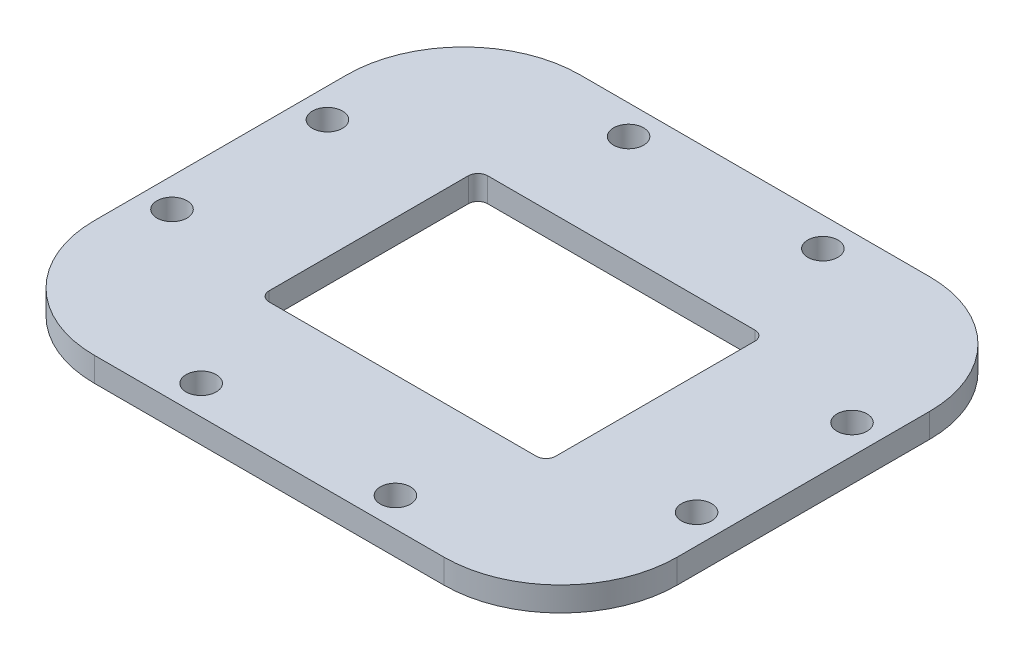
from build123d import *

# Parameters (mm, degrees)
SKETCH_1_W          = 60
SKETCH_1_H          = 50
SKETCH_1_W_2        = 29.5
SKETCH_1_H_2        = 22.5
EXTRUDE_1_DEPTH     = 2.5
SKETCH_8_R          = 1.55
CUT_EXTRUDE_2_DEPTH = 10
FILLET_1_R          = 1
FILLET_2_R          = 12


with BuildPart() as part:
    # 草图1 → 凸台-拉伸1 (new body)
    with BuildSketch(Plane(origin=(0, 0, 0), x_dir=(1, 0, 0), z_dir=(0, 1, 0))):
        Rectangle(SKETCH_1_W, SKETCH_1_H)
        Rectangle(SKETCH_1_W_2, SKETCH_1_H_2, mode=Mode.SUBTRACT)
    extrude(amount=EXTRUDE_1_DEPTH)

    # 草图8 → 切除-拉伸2 (cut)
    with BuildSketch(Plane.XZ):
        with Locations((27, 8)):
            Circle(SKETCH_8_R)
        with Locations((10, 22)):
            Circle(SKETCH_8_R)
        with Locations((-10, 22)):
            Circle(SKETCH_8_R)
        with Locations((-27, 8)):
            Circle(SKETCH_8_R)
        with Locations((-27, -8)):
            Circle(SKETCH_8_R)
        with Locations((-10, -22)):
            Circle(SKETCH_8_R)
        with Locations((10, -22)):
            Circle(SKETCH_8_R)
        with Locations((27, -8)):
            Circle(SKETCH_8_R)
    extrude(amount=-CUT_EXTRUDE_2_DEPTH, mode=Mode.SUBTRACT)

    # 圆角1
    fillet_1_edges = [part.edges().sort_by_distance(p)[0] for p in [
        (14.75, 1.25, 11.25),
        (14.75, 1.25, -11.25),
        (-14.75, 1.25, -11.25),
        (-14.75, 1.25, 11.25),
    ]]
    fillet(fillet_1_edges, radius=FILLET_1_R)

    # 圆角2
    fillet_2_edges = [part.edges().sort_by_distance(p)[0] for p in [
        (30, 1.25, 25),
        (-30, 1.25, 25),
        (-30, 1.25, -25),
        (30, 1.25, -25),
    ]]
    fillet(fillet_2_edges, radius=FILLET_2_R)


solid = part.part
